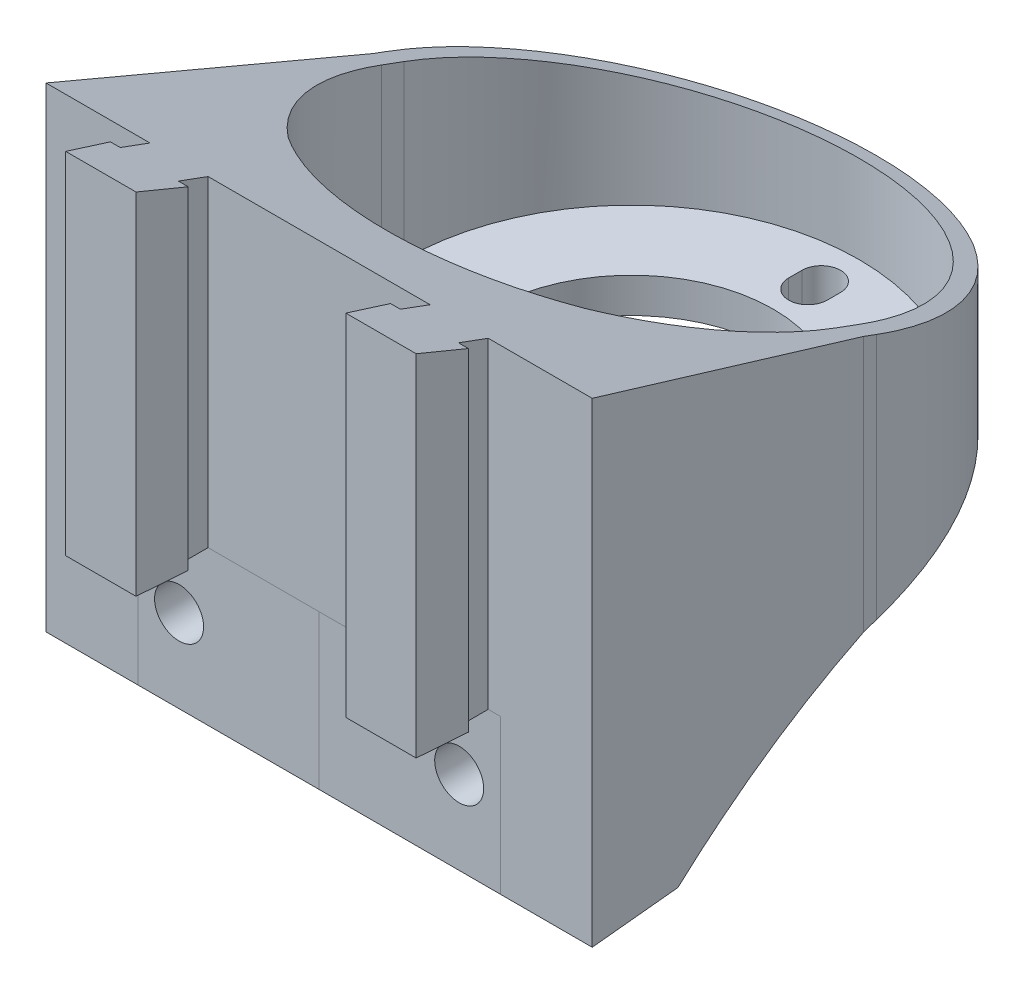
from build123d import *

# Parameters (mm, degrees)
BOSS_EXTRUDE1_DEPTH      = 5
BOSS_EXTRUDE3_DEPTH      = 50
BOSS_EXTRUDE3_DEPTH_BACK = 22
BOSS_EXTRUDE4_DEPTH      = 50
BOSS_EXTRUDE4_DEPTH_BACK = 22
CUT_EXTRUDE3_DEPTH       = 50
SKETCH6_R                = 3.5
CUT_EXTRUDE7_DEPTH       = 74
SKETCH7_R                = 8
CUT_EXTRUDE8_DEPTH       = 35
CUT_EXTRUDE9_DEPTH       = 35


with BuildPart() as part:
    # Sketch1 → Boss-Extrude1 (new body)
    with BuildSketch(Plane(origin=(0, 0, 0), x_dir=(1, 0, 0), z_dir=(0, 1, 0))):
        with BuildLine():
            Line((32.5, 68.476103961), (32.5, 71.691135645))
            ThreePointArc((32.5, 71.691135645), (0, 104.191135645), (-32.5, 71.691135645))
            Line((-32.5, 71.691135645), (-32.5, 68.476103961))
            ThreePointArc((-32.5, 68.476103961), (0, 35.976103961), (32.5, 68.476103961))
        make_face()
        with BuildLine():
            Line((2.75, 43.276103961), (2.75, 41.376103961))
            ThreePointArc((2.75, 41.376103961), (0, 38.626103961), (-2.75, 41.376103961))
            Line((-2.75, 41.376103961), (-2.75, 43.276103961))
            ThreePointArc((-2.75, 43.276103961), (0, 46.026103961), (2.75, 43.276103961))
        make_face(mode=Mode.SUBTRACT)
        with BuildLine():
            ThreePointArc((-20.25, 71.691135645), (0, 91.941135645), (20.25, 71.691135645))
            Line((20.25, 71.691135645), (20.25, 68.476103961))
            ThreePointArc((20.25, 68.476103961), (0, 48.226103961), (-20.25, 68.476103961))
            Line((-20.25, 68.476103961), (-20.25, 71.691135645))
        make_face(mode=Mode.SUBTRACT)
        with BuildLine():
            Line((-28.346988019, 69.121379238), (-28.355451649, 71.021360387))
            ThreePointArc((-28.355451649, 71.021360387), (-25.617728924, 73.783583093), (-22.855506218, 71.045860368))
            Line((-22.855506218, 71.045860368), (-22.847042588, 69.145879219))
            ThreePointArc((-22.847042588, 69.145879219), (-25.584765313, 66.383656513), (-28.346988019, 69.121379238))
        make_face(mode=Mode.SUBTRACT)
        with BuildLine():
            ThreePointArc((22.855506218, 71.045860368), (25.617728924, 73.783583093), (28.355451649, 71.021360387))
            Line((28.355451649, 71.021360387), (28.346988019, 69.121379238))
            ThreePointArc((28.346988019, 69.121379238), (25.584765313, 66.383656513), (22.847042588, 69.145879219))
            Line((22.847042588, 69.145879219), (22.855506218, 71.045860368))
        make_face(mode=Mode.SUBTRACT)
        with BuildLine():
            ThreePointArc((-2.75, 98.791135645), (0, 101.541135645), (2.75, 98.791135645))
            Line((2.75, 98.791135645), (2.75, 96.891135645))
            ThreePointArc((2.75, 96.891135645), (0, 94.141135645), (-2.75, 96.891135645))
            Line((-2.75, 96.891135645), (-2.75, 98.791135645))
        make_face(mode=Mode.SUBTRACT)
    extrude(amount=BOSS_EXTRUDE1_DEPTH)

    # Sketch1_4 → Boss-Extrude3 (add, two sides: drawn at the far end of the back side and taken through both)
    with BuildSketch(Plane(origin=(0, 0, 0), x_dir=(1, 0, 0), z_dir=(0, 1, 0)).offset(-BOSS_EXTRUDE3_DEPTH_BACK)):
        with BuildLine():
            Line((34.993484539, 71.691135645), (34.993484539, 68.476103961))
            ThreePointArc((34.993484539, 68.476103961), (0, 33.482619422), (-34.993484539, 68.476103961))
            Line((-34.993484539, 68.476103961), (-34.993484539, 71.691135645))
            ThreePointArc((-34.993484539, 71.691135645), (0, 106.684620184), (34.993484539, 71.691135645))
        make_face()
        with BuildLine():
            Line((32.5, 71.691135645), (32.5, 68.476103961))
            ThreePointArc((32.5, 68.476103961), (0, 35.976103961), (-32.5, 68.476103961))
            Line((-32.5, 68.476103961), (-32.5, 71.691135645))
            ThreePointArc((-32.5, 71.691135645), (0, 104.191135645), (32.5, 71.691135645))
        make_face(mode=Mode.SUBTRACT)
    extrude(amount=BOSS_EXTRUDE3_DEPTH + BOSS_EXTRUDE3_DEPTH_BACK)

    # Sketch2 → Boss-Extrude4 (add, two sides: drawn at the far end of the back side and taken through both)
    with BuildSketch(Plane(origin=(0, 0, 0), x_dir=(1, 0, 0), z_dir=(0, 1, 0)).offset(-BOSS_EXTRUDE4_DEPTH_BACK)):
        with BuildLine():
            Line((-15.85, 22.838532478), (-14.442663196, 22.838532478))
            Line((-14.442663196, 22.838532478), (-14.977598698, 15.918189547))
            Line((-14.977598698, 15.918189547), (-25.022401302, 15.918189547))
            Line((-25.022401302, 15.918189547), (-25.557336804, 22.838532478))
            Line((-25.557336804, 22.838532478), (-24.15, 22.838532478))
            Line((-24.15, 22.838532478), (-24.15, 27.083619803))
            Line((-24.15, 27.083619803), (-25.25, 27.083619803))
            Line((-25.25, 27.083619803), (-39, 27.083619803))
            Line((-39, 27.083619803), (-34.964708316, 70.119775602))
            ThreePointArc((-34.964708316, 70.119775602), (0, 36.691135645), (34.964708316, 70.119775602))
            Line((34.964708316, 70.119775602), (39, 27.083619803))
            Line((39, 27.083619803), (25.25, 27.083619803))
            Line((25.25, 27.083619803), (24.15, 27.083619803))
            Line((24.15, 27.083619803), (24.15, 22.838532478))
            Line((24.15, 22.838532478), (25.557336804, 22.838532478))
            Line((25.557336804, 22.838532478), (25.022401302, 15.918189547))
            Line((25.022401302, 15.918189547), (14.977598698, 15.918189547))
            Line((14.977598698, 15.918189547), (14.442663196, 22.838532478))
            Line((14.442663196, 22.838532478), (15.85, 22.838532478))
            Line((15.85, 22.838532478), (15.85, 27.083619803))
            Line((15.85, 27.083619803), (14.75, 27.083619803))
            Line((14.75, 27.083619803), (-14.75, 27.083619803))
            Line((-14.75, 27.083619803), (-15.85, 27.083619803))
            Line((-15.85, 27.083619803), (-15.85, 22.838532478))
        make_face()
    extrude(amount=BOSS_EXTRUDE4_DEPTH + BOSS_EXTRUDE4_DEPTH_BACK)

    # Sketch8 → Cut-Extrude3 (cut, symmetric)
    with BuildSketch(Plane(origin=(0, 0, 0), x_dir=(0, 0, -1), z_dir=(1, 0, 0))):
        Polygon((15.918189547, 50), (106.684620184, 50), (106.684620184, 16.610675261), align=None)
        with BuildLine():
            Line((106.684620184, 0), (106.684620184, -22))
            Line((106.684620184, -22), (40.588201897, -22))
            add(Edge.make_bspline(
                [(106.684620184, 0), (69.600838441, -0.610728102), (40.588201897, -22)],
                knots=[0, 0, 0, 1, 1, 1], degree=2))
        make_face()
    extrude(amount=CUT_EXTRUDE3_DEPTH, both=True, mode=Mode.SUBTRACT)

    # Sketch6 → Cut-Extrude7 (cut)
    with BuildSketch(Plane.XY.offset(-70)):
        with Locations((-20, -10.130588175)):
            Circle(SKETCH6_R)
        with Locations((20, -10.130588175)):
            Circle(SKETCH6_R)
    extrude(amount=CUT_EXTRUDE7_DEPTH, mode=Mode.SUBTRACT)

    # Sketch7 → Cut-Extrude8 (cut)
    with BuildSketch(Plane.XY.offset(-70)):
        with Locations((-20, -10.125507159)):
            Circle(SKETCH7_R)
        with Locations((20, -10.125507159)):
            Circle(SKETCH7_R)
    extrude(amount=CUT_EXTRUDE8_DEPTH, mode=Mode.SUBTRACT)

    # Sketch4 → Cut-Extrude9 (cut)
    with BuildSketch(Plane(origin=(0, 0, 0), x_dir=(1, 0, 0), z_dir=(0, 1, 0))):
        Polygon((25.88119751, 27.083619803), (-2e-09, 27.101118051), (-25.88119751, 27.083619803), (-32.125, 22.89108437), (-32.33386562, 13.718189547), (0, 13.918189547), (32.33386562, 13.718189547), (32.125, 22.89108437), align=None)
    extrude(amount=-CUT_EXTRUDE9_DEPTH, mode=Mode.SUBTRACT)


solid = part.part
